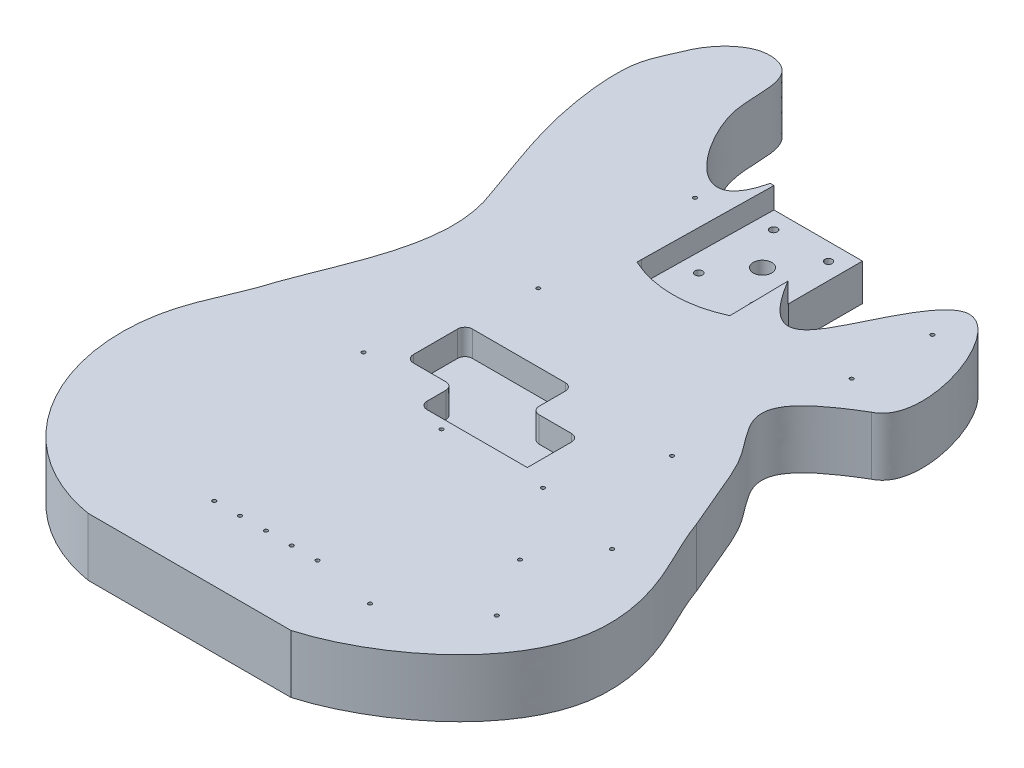
from build123d import *

# Parameters (mm, degrees)
BOSS_EXTRUDE1_DEPTH = 40.005
CUT_EXTRUDE1_DEPTH  = 14.605
SKETCH3_R           = 6.35
SKETCH3_R_2         = 2.54
CUT_EXTRUDE2_DEPTH  = 26.4000001
CUT_EXTRUDE3_DEPTH  = 17.5514
SKETCH5_R           = 1.27
CUT_EXTRUDE4_DEPTH  = 17.78


with BuildPart() as part:
    # Sketch1 → Boss-Extrude1 (new body)
    with BuildSketch(Plane(origin=(0, 0, 0), x_dir=(1, 0, 0), z_dir=(0, 1, 0))):
        with BuildLine():
            Line((-31.75, 431.8), (31.75, 431.8))
            Line((31.75, 431.8), (31.75, 381))
            add(Edge.make_bspline(
                [(139.7, 330.2), (166.445933937, 342.89199921), (123.503776034, 464.530793204), (76.812686628, 369.38946014), (59.509313942, 333.666820551), (31.75, 381)],
                knots=[0, 0, 0, 0, 0.451982316, 0.679896033, 1, 1, 1, 1], degree=3))
            add(Edge.make_bspline(
                [(146.05, 203.2), (136.159858324, 225.650446788), (132.589610525, 236.847424982), (120.383558334, 260.933031596), (109.568716266, 273.359552136), (96.590167779, 297.02427137), (109.096273913, 311.992671669), (139.7, 330.2)],
                knots=[0, 0, 0, 0, 0.338979618, 0.396393174, 0.554386404, 0.616722002, 1, 1, 1, 1], degree=3))
            add(Edge.make_bspline(
                [(69.85, 0), (111.934817577, 12.111106324), (186.014505262, 65.749693466), (170.841604559, 155.498343774), (152.338106065, 185.626315347), (146.05, 203.2)],
                knots=[0, 0, 0, 0, 0.586136039, 0.784814246, 1, 1, 1, 1], degree=3))
            Line((69.85, 0), (-69.85, 0))
            add(Edge.make_bspline(
                [(-69.85, 0), (-122.745853908, 8.894627237), (-170.373818617, 68.373598191), (-165.531190573, 154.759290659), (-147.834713243, 185.810503286), (-142.875, 203.2)],
                knots=[0, 0, 0, 0, 0.581043163, 0.78383742, 1, 1, 1, 1], degree=3))
            add(Edge.make_bspline(
                [(-142.875, 203.2), (-128.639770906, 243.099083108), (-104.490445622, 285.950192917), (-122.2248, 330.2)],
                knots=[0, 0, 0, 0, 1, 1, 1, 1], degree=3))
            add(Edge.make_bspline(
                [(-122.2248, 330.2), (-131.763508886, 357.856604277), (-146.2425508, 392.351504834), (-152.772633421, 455.278086227), (-144.543275129, 471.013225285), (-135.470443556, 492.861244858), (-120.651127827, 508.750910027), (-90.829721956, 507.317797539), (-88.364588713, 481.720202384), (-88.704714068, 444.441923985), (-43.011483466, 384.645662013), (-31.75, 431.8)],
                knots=[0, 0, 0, 0, 0.228270644, 0.373680854, 0.455314812, 0.473381506, 0.54535154, 0.564858815, 0.659457996, 0.74420055, 1, 1, 1, 1], degree=3))
        make_face()
    extrude(amount=BOSS_EXTRUDE1_DEPTH)

    # Sketch2 → Cut-Extrude1 (cut)
    with BuildSketch(Plane(origin=(0, 40.005, 0), x_dir=(1, 0, 0), z_dir=(0, 1, 0))):
        with BuildLine():
            Line((-29.21, 431.8), (31.75, 431.8))
            Line((31.75, 431.8), (33.2232, 341.9475))
            Line((33.2232, 341.9475), (33.2232, 338.8995))
            ThreePointArc((33.2232, 338.8995), (1.27, 331.7875), (-30.6832, 338.8995))
            Line((-30.6832, 338.8995), (-30.6832, 341.9475))
            Line((-30.6832, 341.9475), (-29.21, 431.8))
        make_face()
    extrude(amount=-CUT_EXTRUDE1_DEPTH, mode=Mode.SUBTRACT)

    # Sketch3 → Cut-Extrude2 (cut, through all)
    with BuildSketch(Plane(origin=(0, 25.4, 0), x_dir=(1, 0, 0), z_dir=(0, 1, 0))):
        with Locations((1.27, 393.3952)):
            Circle(SKETCH3_R)
        with Locations((-17.526, 419.862)):
            Circle(SKETCH3_R_2)
        with Locations((20.2692, 419.862)):
            Circle(SKETCH3_R_2)
        with Locations((20.59715074, 368.3)):
            Circle(SKETCH3_R_2)
        with Locations((-17.549082464, 368.3)):
            Circle(SKETCH3_R_2)
    extrude(amount=-CUT_EXTRUDE2_DEPTH, mode=Mode.SUBTRACT)

    # Sketch4 → Cut-Extrude3 (cut)
    with BuildSketch(Plane(origin=(0, 40.005, 0), x_dir=(1, 0, 0), z_dir=(0, 1, 0))):
        with BuildLine():
            Line((-47.498, 242.316), (16.51, 242.316))
            ThreePointArc((16.51, 242.316), (20.102102448, 240.828102448), (21.59, 237.236))
            Line((21.59, 237.236), (21.59, 219.202))
            ThreePointArc((21.59, 219.202), (23.077897552, 215.609897552), (26.67, 214.122))
            Line((26.67, 214.122), (49.022, 214.122))
            ThreePointArc((49.022, 214.122), (52.614102448, 212.634102448), (54.102, 209.042))
            Line((54.102, 209.042), (54.102, 178.562))
            Line((54.102, 178.562), (-14.986, 178.562))
            ThreePointArc((-14.986, 178.562), (-18.578102448, 180.049897552), (-20.066, 183.642))
            Line((-20.066, 183.642), (-20.066, 196.596))
            ThreePointArc((-20.066, 196.596), (-21.553897552, 200.188102448), (-25.146, 201.676))
            Line((-25.146, 201.676), (-47.498, 201.676))
            ThreePointArc((-47.498, 201.676), (-51.090102448, 203.163897552), (-52.578, 206.756))
            Line((-52.578, 206.756), (-52.578, 237.236))
            ThreePointArc((-52.578, 237.236), (-51.090102448, 240.828102448), (-47.498, 242.316))
        make_face()
    extrude(amount=-CUT_EXTRUDE3_DEPTH, mode=Mode.SUBTRACT)

    # Sketch5 → Cut-Extrude4 (cut)
    with BuildSketch(Plane(origin=(0, 40.005, 0), x_dir=(1, 0, 0), z_dir=(0, 1, 0))):
        with Locations((-49.082798919, 397.256)):
            Circle(SKETCH5_R)
        with Locations((-49.082798919, 289.306)):
            Circle(SKETCH5_R)
        with Locations((-70.990298919, 190.881)):
            Circle(SKETCH5_R)
        with Locations((112.842201081, 343.281)):
            Circle(SKETCH5_R)
        with Locations((114.417001081, 397.256)):
            Circle(SKETCH5_R)
        with Locations((96.967201081, 235.331)):
            Circle(SKETCH5_R)
        with Locations((131.892201081, 159.131)):
            Circle(SKETCH5_R)
        with Locations((131.892201081, 79.756)):
            Circle(SKETCH5_R)
        with Locations((81.092201081, 43.2435)):
            Circle(SKETCH5_R)
        with Locations((106.492201081, 121.031)):
            Circle(SKETCH5_R)
        with Locations((71.567201081, 171.831)):
            Circle(SKETCH5_R)
        with Locations((-33.842798919, 50.8508)):
            Circle(SKETCH5_R)
        with Locations((-16.062798919, 50.8508)):
            Circle(SKETCH5_R)
        with Locations((1.717201081, 50.8508)):
            Circle(SKETCH5_R)
        with Locations((19.497201081, 50.8508)):
            Circle(SKETCH5_R)
        with Locations((37.277201081, 50.8508)):
            Circle(SKETCH5_R)
        with Locations((1.717201081, 171.831)):
            Circle(SKETCH5_R)
    extrude(amount=-CUT_EXTRUDE4_DEPTH, mode=Mode.SUBTRACT)


solid = part.part
